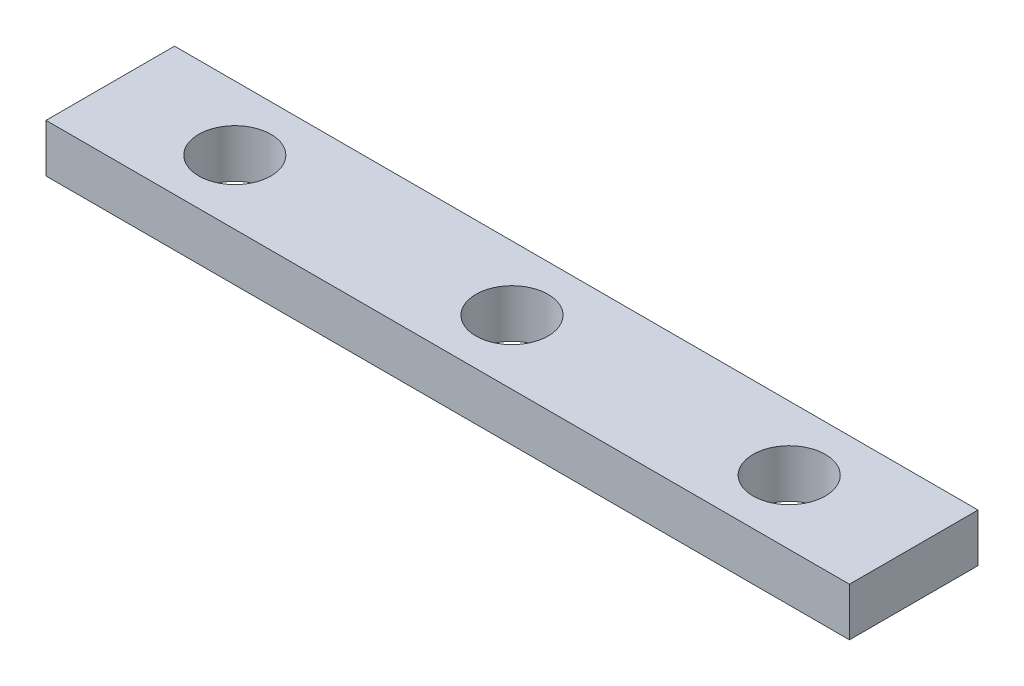
from build123d import *

# Parameters (mm, degrees)
SKETCH1_W                 = 50
SKETCH1_H                 = 8
BOSS_EXTRUDE1_DEPTH       = 3
F_8_CLEARANCE_HOLE1_D     = 4.4958
F_8_CLEARANCE_HOLE1_DEPTH = 17
F_8_CLEARANCE_HOLE1_TIP   = 1.350674586


with BuildPart() as part:
    # Sketch1 → Boss-Extrude1 (new body)
    with BuildSketch(Plane(origin=(0, 0, 0), x_dir=(1, 0, 0), z_dir=(0, 1, 0))):
        with Locations((17.773632998, 0.313559322)):
            Rectangle(SKETCH1_W, SKETCH1_H)
    extrude(amount=BOSS_EXTRUDE1_DEPTH)

    # #8 Clearance Hole1
    with Locations(Plane(origin=(0.523632998, 3, -0.313559322), x_dir=(0, 0, 1), z_dir=(0, 1, 0))):
        with Locations((0, 0), (0, 34.5), (0, 17.25)):
            Hole(F_8_CLEARANCE_HOLE1_D / 2, depth=F_8_CLEARANCE_HOLE1_DEPTH)
            with Locations((0, 0, -(F_8_CLEARANCE_HOLE1_DEPTH + F_8_CLEARANCE_HOLE1_TIP / 2))):  # 118° drill point
                Cone(0, F_8_CLEARANCE_HOLE1_D / 2, F_8_CLEARANCE_HOLE1_TIP, mode=Mode.SUBTRACT)


solid = part.part
